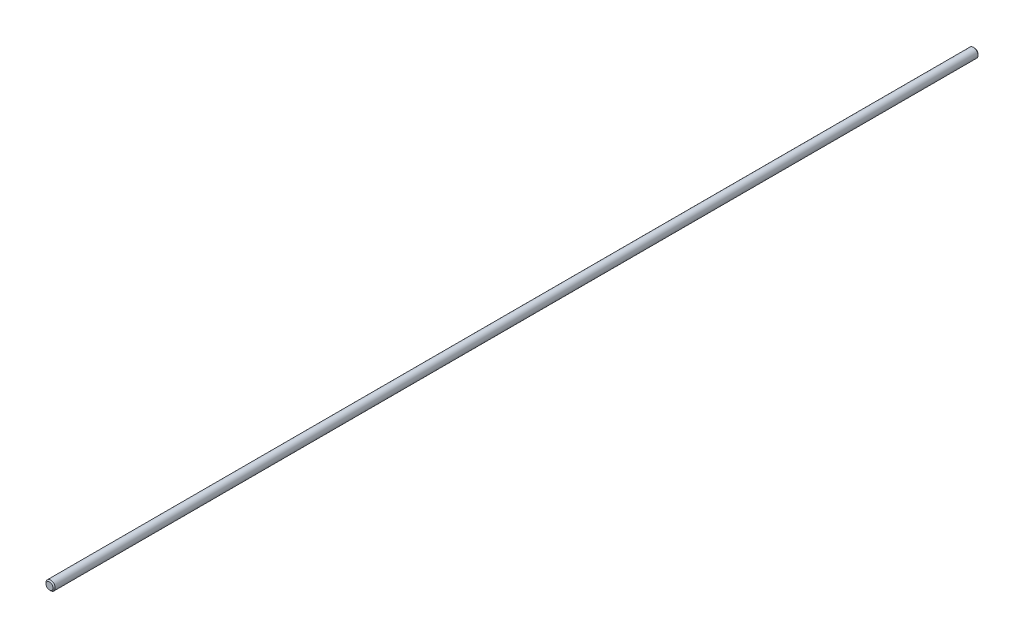
from build123d import *

# Parameters (mm, degrees)
SKETCH2_W     = 500
SKETCH2_H     = 2.5
CHAMFER1_SIZE = 0.6


with BuildPart() as part:
    # Sketch2 → Revolve1 (revolve)
    with BuildSketch(Plane(origin=(0, 0, 0), x_dir=(0, 0, -1), z_dir=(1, 0, 0))):
        with Locations((0, 1.25)):
            Rectangle(SKETCH2_W, SKETCH2_H)
    revolve(axis=Axis((0, 0, 250), (0, 0, -1)))

    # Chamfer1
    chamfer1_edges = [part.edges().sort_by_distance(p)[0] for p in [
        (0, -2.5, -250),
        (0, -2.5, 250),
    ]]
    chamfer(chamfer1_edges, length=CHAMFER1_SIZE)


solid = part.part
